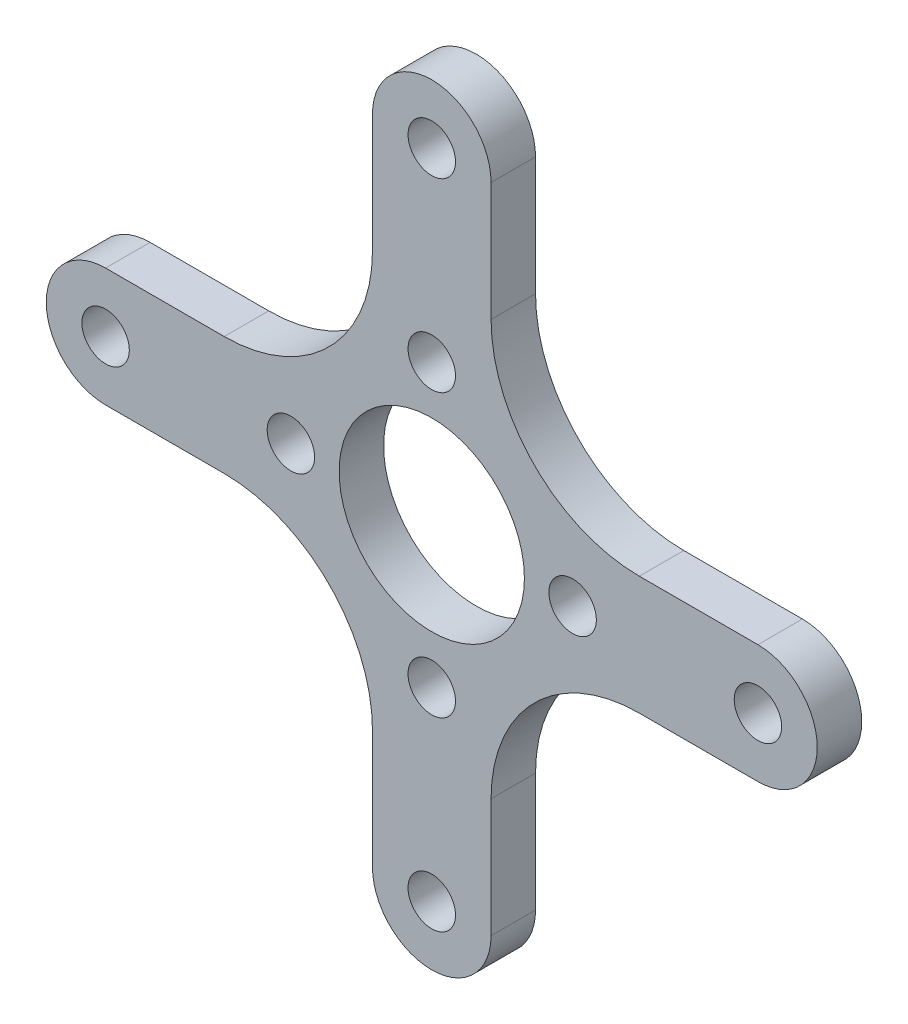
from build123d import *

# Parameters (mm, degrees)
SKETCH_1_R      = 6.25
SKETCH_1_R_2    = 1.6
EXTRUDE_1_DEPTH = 1.5


with BuildPart() as part:
    # Эскиз1 → Бобышка-Вытянуть1 (new body, symmetric)
    with BuildSketch(Plane.XY):
        with BuildLine():
            Line((-22, 4), (-14, 4))
            ThreePointArc((-14, 4), (-6.928932188, 6.928932188), (-4, 14))
            Line((-4, 14), (-4, 22))
            ThreePointArc((-4, 22), (0, 26), (4, 22))
            Line((4, 22), (4, 14))
            ThreePointArc((4, 14), (6.928932188, 6.928932188), (14, 4))
            Line((14, 4), (22, 4))
            ThreePointArc((22, 4), (26, 0), (22, -4))
            Line((22, -4), (14, -4))
            ThreePointArc((14, -4), (6.928932188, -6.928932188), (4, -14))
            Line((4, -14), (4, -22))
            ThreePointArc((4, -22), (0, -26), (-4, -22))
            Line((-4, -22), (-4, -14))
            ThreePointArc((-4, -14), (-6.928932188, -6.928932188), (-14, -4))
            Line((-14, -4), (-22, -4))
            ThreePointArc((-22, -4), (-26, 0), (-22, 4))
        make_face()
        Circle(SKETCH_1_R, mode=Mode.SUBTRACT)
        with Locations((-9.5, 0)):
            Circle(SKETCH_1_R_2, mode=Mode.SUBTRACT)
        with Locations((-22, 0)):
            Circle(SKETCH_1_R_2, mode=Mode.SUBTRACT)
        with Locations((0, 9.5)):
            Circle(SKETCH_1_R_2, mode=Mode.SUBTRACT)
        with Locations((0, 22)):
            Circle(SKETCH_1_R_2, mode=Mode.SUBTRACT)
        with Locations((9.5, 0)):
            Circle(SKETCH_1_R_2, mode=Mode.SUBTRACT)
        with Locations((22, 0)):
            Circle(SKETCH_1_R_2, mode=Mode.SUBTRACT)
        with Locations((0, -22)):
            Circle(SKETCH_1_R_2, mode=Mode.SUBTRACT)
        with Locations((0, -9.5)):
            Circle(SKETCH_1_R_2, mode=Mode.SUBTRACT)
    extrude(amount=EXTRUDE_1_DEPTH, both=True)


solid = part.part
